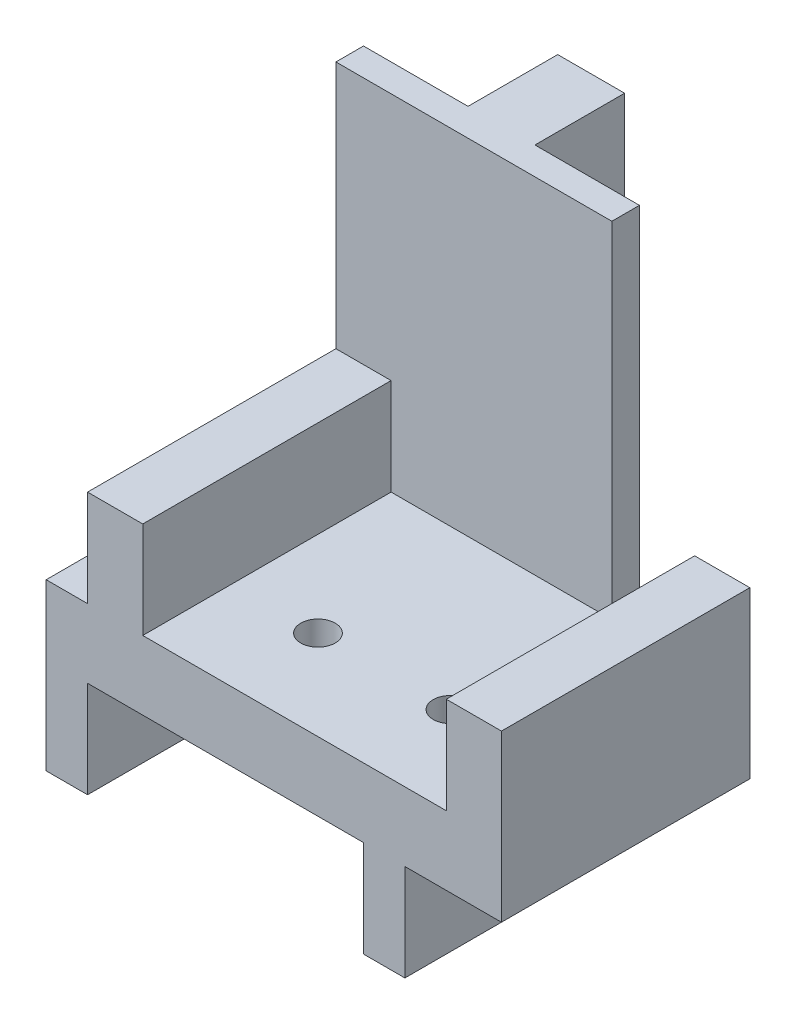
from build123d import *

# Parameters (mm, degrees)
EXTRUDE_1_DEPTH     = 18
SKETCH_3_W          = 20
SKETCH_3_H          = 30
EXTRUDE_2_DEPTH     = 2
SKETCH_4_W          = 4.85
SKETCH_4_H          = 30
EXTRUDE_3_DEPTH     = 6.5
EXTRUDE_START       = -20
SKETCH_5_W          = 3
SKETCH_5_H          = 12
EXTRUDE_4_DEPTH     = 20
SKETCH_2_R          = 1.25
CUT_EXTRUDE_1_DEPTH = 18


with BuildPart() as part:
    # 스케치1 → 보스-돌출1 (new body)
    with BuildSketch(Plane.XY):
        Polygon((-15, 12), (-15, 0), (15, 0), (15, 12), (11, 12), (11, 5), (-11, 5), (-11, 12), align=None)
    extrude(amount=EXTRUDE_1_DEPTH)

    # 스케치3 → 보스-돌출2 (add)
    with BuildSketch(Plane(origin=(0, 0, 0), x_dir=(-1, 0, 0), z_dir=(0, 0, -1))):
        with Locations((5, 15)):
            Rectangle(SKETCH_3_W, SKETCH_3_H)
    extrude(amount=EXTRUDE_2_DEPTH)

    # 스케치4 → 보스-돌출3 (add)
    with BuildSketch(Plane(origin=(0, 0, -2), x_dir=(-1, 0, 0), z_dir=(0, 0, -1))):
        with Locations((5, 15)):
            Rectangle(SKETCH_4_W, SKETCH_4_H)
    extrude(amount=EXTRUDE_3_DEPTH)

    # 스케치5 → 보스-돌출4 (add)
    with BuildSketch(Plane.XY.offset(18).offset(EXTRUDE_START)):
        with Locations((-16.5, -1)):
            Rectangle(SKETCH_5_W, SKETCH_5_H)
        with Locations((6.5, -1)):
            Rectangle(SKETCH_5_W, SKETCH_5_H)
    extrude(amount=EXTRUDE_4_DEPTH)

    # 스케치2 → 컷-돌출1 (cut)
    with BuildSketch(Plane(origin=(0, 5, 0), x_dir=(1, 0, 0), z_dir=(0, 1, 0))):
        with Locations((-4.8, -11.5)):
            Circle(SKETCH_2_R)
        with Locations((4.8, -11.5)):
            Circle(SKETCH_2_R)
    extrude(amount=-CUT_EXTRUDE_1_DEPTH, mode=Mode.SUBTRACT)


solid = part.part
